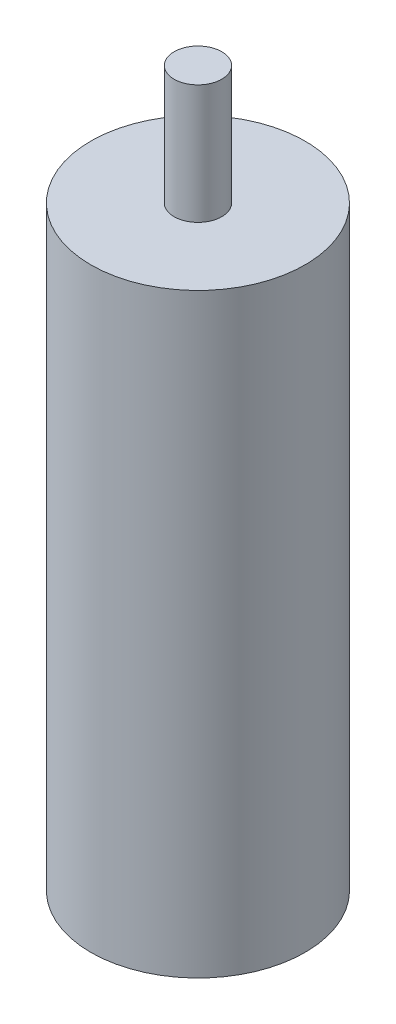
from build123d import *

# Parameters (mm, degrees)
SKETCH1_R           = 22.5
BOSS_EXTRUDE1_DEPTH = 125
SKETCH2_R           = 5
BOSS_EXTRUDE2_DEPTH = 25


with BuildPart() as part:
    # Sketch1 → Boss-Extrude1 (new body)
    with BuildSketch(Plane(origin=(0, 0, 0), x_dir=(1, 0, 0), z_dir=(0, 1, 0))):
        Circle(SKETCH1_R)
    extrude(amount=BOSS_EXTRUDE1_DEPTH)

    # Sketch2 → Boss-Extrude2 (add)
    with BuildSketch(Plane(origin=(0, 125, 0), x_dir=(1, 0, 0), z_dir=(0, 1, 0))):
        Circle(SKETCH2_R)
    extrude(amount=BOSS_EXTRUDE2_DEPTH)


solid = part.part
